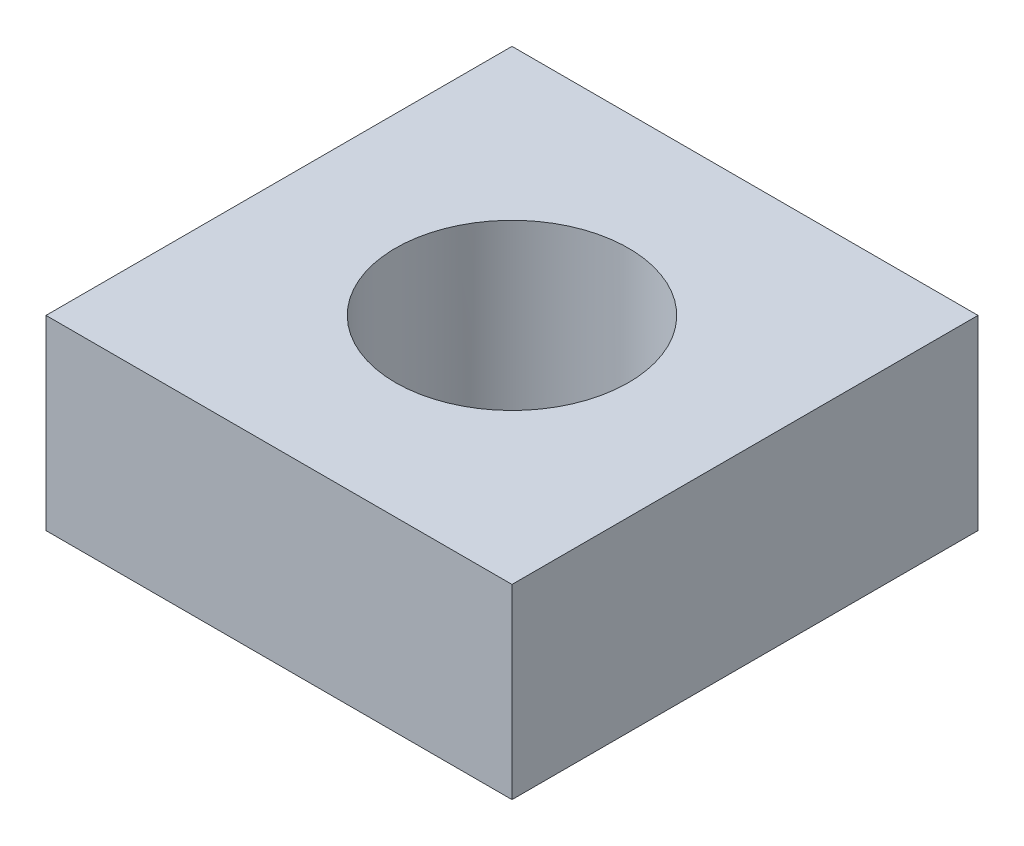
from build123d import *

# Parameters (mm, degrees)
SKETCH1_W           = 50
SKETCH1_H           = 50
BOSS_EXTRUDE1_DEPTH = 20
SKETCH2_R           = 12.5
CUT_EXTRUDE1_DEPTH  = 30


with BuildPart() as part:
    # Sketch1 → Boss-Extrude1 (new body)
    with BuildSketch(Plane(origin=(0, 0, 0), x_dir=(1, 0, 0), z_dir=(0, 1, 0))):
        with Locations((25, 25)):
            Rectangle(SKETCH1_W, SKETCH1_H)
    extrude(amount=BOSS_EXTRUDE1_DEPTH)

    # Sketch2 → Cut-Extrude1 (cut)
    with BuildSketch(Plane(origin=(0, 20, 0), x_dir=(1, 0, 0), z_dir=(0, 1, 0))):
        with Locations((25, 25)):
            Circle(SKETCH2_R)
    extrude(amount=-CUT_EXTRUDE1_DEPTH, mode=Mode.SUBTRACT)


solid = part.part
